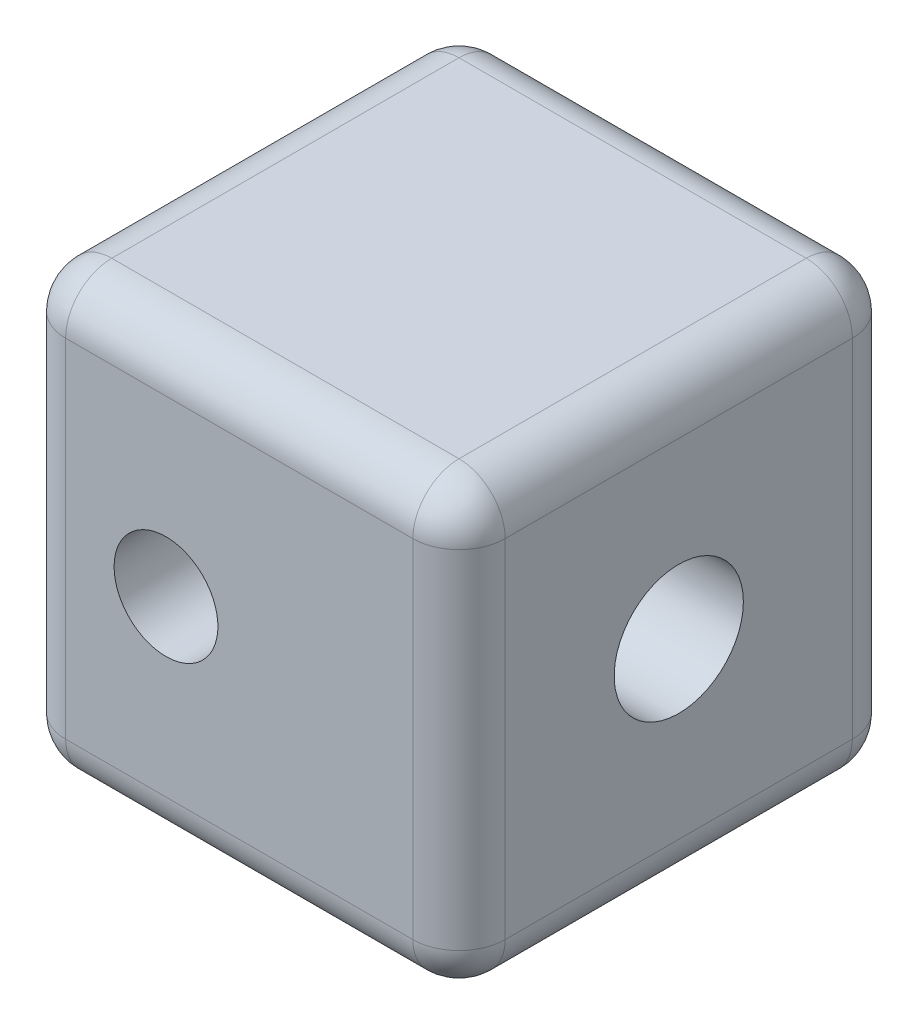
from build123d import *

# Parameters (mm, degrees)
SKETCH1_W           = 19.05
SKETCH1_H           = 19.05
SKETCH1_R           = 6.35
BOSS_EXTRUDE1_DEPTH = 12.7
SKETCH3_W           = 19.05
SKETCH3_H           = 19.05
BOSS_EXTRUDE2_DEPTH = 6.35
SKETCH5_R           = 2.8
CUT_EXTRUDE1_DEPTH  = 7
SKETCH6_R           = 4.6
BOSS_EXTRUDE4_DEPTH = 12.7
CUT_EXTRUDE2_DEPTH  = 55
FILLET1_R           = 1
FILLET2_R           = 2
SKETCH9_R           = 2.25
CUT_EXTRUDE3_DEPTH  = 2


with BuildPart() as part:
    # Sketch1 → Boss-Extrude1 (new body)
    with BuildSketch(Plane(origin=(0, 0, 0), x_dir=(0, 0, -1), z_dir=(1, 0, 0))):
        Rectangle(SKETCH1_W, SKETCH1_H)
        Circle(SKETCH1_R, mode=Mode.SUBTRACT)
    extrude(amount=BOSS_EXTRUDE1_DEPTH)

    # Sketch3 → Boss-Extrude2 (add)
    with BuildSketch(Plane(origin=(12.7, 0, 0), x_dir=(0, 0, -1), z_dir=(1, 0, 0))):
        Rectangle(SKETCH3_W, SKETCH3_H)
    extrude(amount=BOSS_EXTRUDE2_DEPTH)

    # Sketch5 → Cut-Extrude1 (cut)
    with BuildSketch(Plane(origin=(19.05, 0, 0), x_dir=(0, 0, -1), z_dir=(1, 0, 0))):
        Circle(SKETCH5_R)
    extrude(amount=-CUT_EXTRUDE1_DEPTH, mode=Mode.SUBTRACT)

    # Sketch6 → Boss-Extrude4 (add)
    with BuildSketch(Plane.ZY.offset(-12.7)):
        Circle(SKETCH6_R)
    extrude(amount=BOSS_EXTRUDE4_DEPTH)

    # Sketch8 → Cut-Extrude2 (cut)
    with BuildSketch(Plane(origin=(0, 0, -9.525), x_dir=(-1, 0, 0), z_dir=(0, 0, -1))):
        with BuildLine():
            ThreePointArc((-4.1, 0), (-6.35, 2.25), (-8.6, 0))
            Line((-8.6, 0), (-4.1, 0))
        make_face()
        with BuildLine():
            Line((-4.1, 0), (-8.6, 0))
            ThreePointArc((-8.6, 0), (-6.35, -2.25), (-4.1, 0))
        make_face()
    extrude(amount=-CUT_EXTRUDE2_DEPTH, mode=Mode.SUBTRACT)

    # Fillet1
    fillet1_edges = [part.edges().sort_by_distance(p)[0] for p in [
        (0, 0, 6.35),
        (0, 0, -4.6),
    ]]
    fillet(fillet1_edges, radius=FILLET1_R)

    # Fillet2
    fillet2_edges = [part.edges().sort_by_distance(p)[0] for p in [
        (19.05, 9.525, 0),
        (19.05, 0, 9.525),
        (19.05, -9.525, 0),
        (19.05, 0, -9.525),
        (0, 9.525, 0),
        (0, 0, -9.525),
        (0, -9.525, 0),
        (0, 0, 9.525),
        (9.525, 9.525, 9.525),
        (9.525, 9.525, -9.525),
        (9.525, -9.525, -9.525),
        (9.525, -9.525, 9.525),
    ]]
    fillet(fillet2_edges, radius=FILLET2_R)

    # Sketch9 → Cut-Extrude3 (cut)
    with BuildSketch(Plane(origin=(0, 0, -9.525), x_dir=(-1, 0, 0), z_dir=(0, 0, -1))):
        Polygon((-9.85, 2.020725942), (-9.85, -2.020725942), (-6.35, -4.041451884), (-2.85, -2.020725942), (-2.85, 2.020725942), (-6.35, 4.041451884), align=None)
        with Locations((-6.35, 0)):
            Circle(SKETCH9_R, mode=Mode.SUBTRACT)
    extrude(amount=-CUT_EXTRUDE3_DEPTH, mode=Mode.SUBTRACT)


solid = part.part
